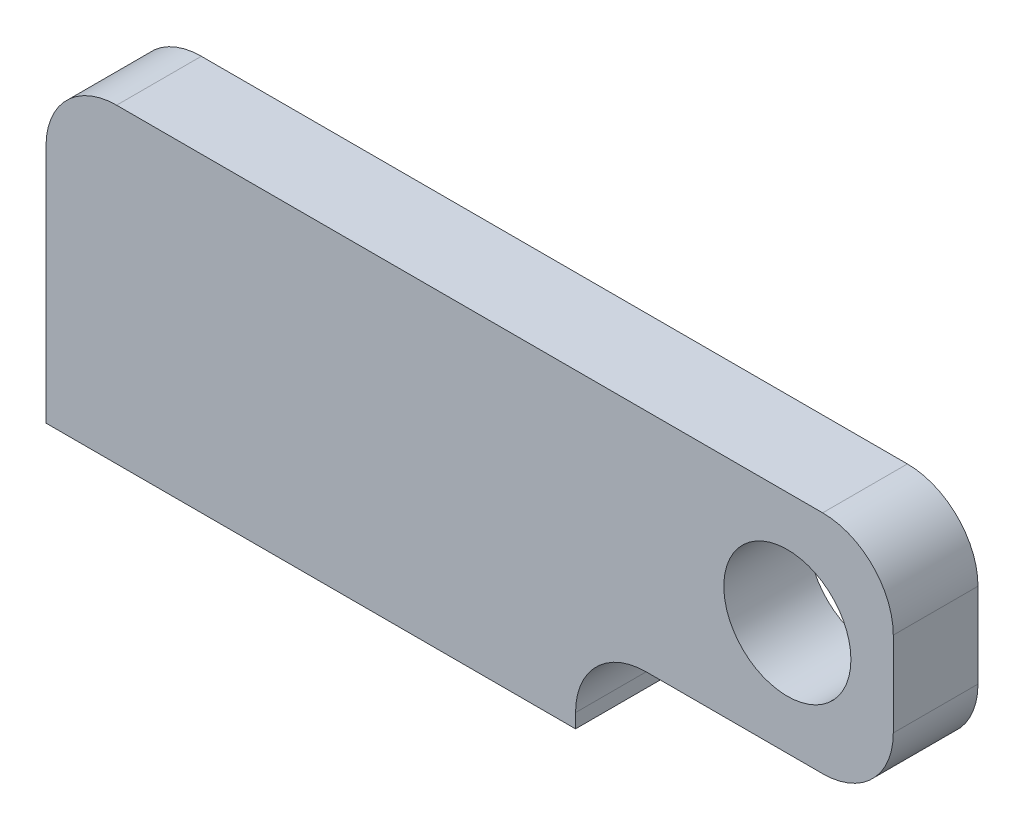
from build123d import *

# Parameters (mm, degrees)
EXTRUDE_1_DEPTH        = 6
HOLE_WIZARD_M6_1_D     = 5
HOLE_WIZARD_M6_1_DEPTH = 18
HOLE_WIZARD_M6_1_TIP   = 1.502151548
SKETCH_4_R             = 9
CUT_EXTRUDE_1_DEPTH    = 13
FILLET_1_R             = 10


with BuildPart() as part:
    # 草图1 → 凸台-拉伸1 (new body, symmetric)
    with BuildSketch(Plane.XY):
        Polygon((0, 0), (75, 0), (75, 12), (120, 12), (120, 44), (0, 44), align=None)
    extrude(amount=EXTRUDE_1_DEPTH, both=True)

    # M6 螺纹孔1
    with Locations(Plane(origin=(0, 0, 0), x_dir=(-1, 0, 0), z_dir=(0, -1, 0))):
        with Locations((-10, 0), (-65, 0)):
            Hole(HOLE_WIZARD_M6_1_D / 2, depth=HOLE_WIZARD_M6_1_DEPTH)
            with Locations((0, 0, -(HOLE_WIZARD_M6_1_DEPTH + HOLE_WIZARD_M6_1_TIP / 2))):  # 118° drill point
                Cone(0, HOLE_WIZARD_M6_1_D / 2, HOLE_WIZARD_M6_1_TIP, mode=Mode.SUBTRACT)

    # 草图4 → 切除-拉伸1 (cut, through all)
    with BuildSketch(Plane.XY.offset(6)):
        with Locations((105, 28)):
            Circle(SKETCH_4_R)
    extrude(amount=-CUT_EXTRUDE_1_DEPTH, mode=Mode.SUBTRACT)

    # 圆角1
    fillet_1_edges = [part.edges().sort_by_distance(p)[0] for p in [
        (0, 44, 0),
        (120, 44, 0),
        (120, 12, 0),
        (75, 12, 0),
    ]]
    fillet(fillet_1_edges, radius=FILLET_1_R)


solid = part.part
